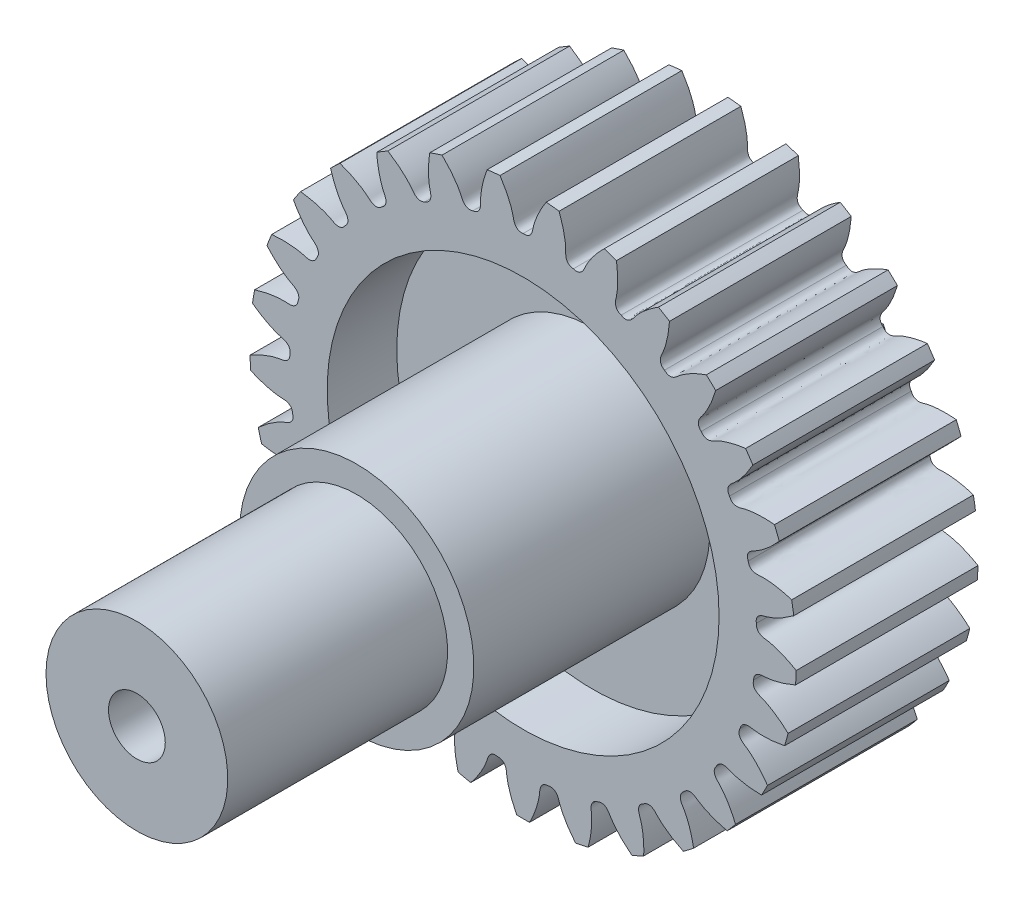
from build123d import *

# Parameters (mm, degrees)
GEAR_BASESKETCH_R                            = 9.62085945
F_0_6207_MODULE_18_0003MM_P_D_DEPTH          = 3.2
TOOTH_CUT_COARSE_PITCH_INVOLUTE_20_DEG_DEPTH = 4.2
TOOTH_PATTERN_29_29_COUNT                    = 29
SKETCH3_R                                    = 6.9
CUT_EXTRUDE5_DEPTH                           = 7.4000001
SKETCH5_R                                    = 1
CUT_EXTRUDE6_DEPTH                           = 23
BOSS_EXTRUDE2_DEPTH                          = 2.5


with BuildPart() as part:
    # Gear-BaseSketch → 0.6207 Module, 18.0003mm P.D. (new body, symmetric)
    with BuildSketch(Plane.XY):
        Circle(GEAR_BASESKETCH_R)
    extrude(amount=F_0_6207_MODULE_18_0003MM_P_D_DEPTH, both=True)

    # Tooth-Sketch; Backlash: 0.0000mm → Tooth-Cut, Coarse Pitch Involute 20 deg (cut, symmetric)
    with BuildSketch(Plane.XY):
        with BuildLine():
            ThreePointArc((-0.874573512, 9.677174392), (0, 9.716613764), (0.874573512, 9.677174392))
            add(Edge.make_bspline(
                [(0.874573512, 9.677174392), (0.810753253, 9.584844464), (0.723074056, 9.448048962), (0.621038779, 9.266226692), (0.557931311, 9.143132279), (0.504580396, 9.02865349), (0.460240286, 8.923335386), (0.42413615, 8.827679054), (0.395475422, 8.742139085), (0.37342353, 8.667126443), (0.357185949, 8.602995588), (0.347105284, 8.55622554), (0.341425051, 8.524655339), (0.337449721, 8.504838192), (0.330655529, 8.475214631), (0.319198264, 8.435173705), (0.299395753, 8.3855185), (0.272391469, 8.337048944), (0.233306546, 8.289093251), (0.149065118, 8.22525123), (0.058572624, 8.218421439), (0, 8.223999693)],
                knots=[0, 0, 0, 0, 0.188221103, 0.272248381, 0.349553478, 0.420136393, 0.483997126, 0.541135677, 0.591552047, 0.635246236, 0.672218243, 0.70246807, 0.715453139, 0.726008681, 0.736358508, 0.766417562, 0.795747205, 0.825830737, 0.85909947, 0.898928891, 1, 1, 1, 1], degree=3))
            add(Edge.make_bspline(
                [(-0.874573512, 9.677174392), (-0.810753253, 9.584844464), (-0.723074056, 9.448048962), (-0.621038779, 9.266226692), (-0.557931311, 9.143132279), (-0.504580396, 9.02865349), (-0.460240286, 8.923335386), (-0.42413615, 8.827679054), (-0.395475422, 8.742139085), (-0.37342353, 8.667126443), (-0.357185949, 8.602995588), (-0.347105284, 8.55622554), (-0.341425051, 8.524655339), (-0.337449721, 8.504838192), (-0.330655529, 8.475214631), (-0.319198264, 8.435173705), (-0.299395753, 8.3855185), (-0.272391469, 8.337048944), (-0.233306546, 8.289093251), (-0.149065118, 8.22525123), (-0.058572624, 8.218421439), (0, 8.223999693)],
                knots=[0, 0, 0, 0, 0.188221103, 0.272248381, 0.349553478, 0.420136393, 0.483997126, 0.541135677, 0.591552047, 0.635246236, 0.672218243, 0.70246807, 0.715453139, 0.726008681, 0.736358508, 0.766417562, 0.795747205, 0.825830737, 0.85909947, 0.898928891, 1, 1, 1, 1], degree=3))
        make_face()
    tooth_cut_coarse_pitch_involute_20_deg = extrude(amount=TOOTH_CUT_COARSE_PITCH_INVOLUTE_20_DEG_DEPTH, both=True, mode=Mode.SUBTRACT)

    # Tooth Pattern, 29 / 29: Tooth-Cut, Coarse Pitch Involute 20 deg ×29 about axis
    tooth_pattern_29_29_axis = Axis((0, 0, -88.99), (0, 0, 1))
    for i in range(1, TOOTH_PATTERN_29_29_COUNT):
        add(tooth_cut_coarse_pitch_involute_20_deg.rotate(tooth_pattern_29_29_axis, i * 360 / TOOTH_PATTERN_29_29_COUNT), mode=Mode.SUBTRACT)

    # Sketch3 → Cut-Extrude5 (cut, through all)
    with BuildSketch(Plane.XY.offset(3.2)):
        Circle(SKETCH3_R)
    extrude(amount=-CUT_EXTRUDE5_DEPTH, mode=Mode.SUBTRACT)

    # Sketch4 → Revolve1 (revolve)
    with BuildSketch(Plane(origin=(0, 0, 0), x_dir=(1, 0, 0), z_dir=(0, 1, 0))):
        Polygon((0, 5.2), (3.25, 5.2), (3.25, 0.75), (6.9, 0.75), (6.9, -0.75), (4.125, -0.75), (4.125, -9.06), (3.2, -9.06), (3.2, -16.8), (0, -16.8), align=None)
    revolve(axis=Axis((0, 0, -88.99), (0, 0, 1)))

    # Sketch5 → Cut-Extrude6 (cut, through all)
    with BuildSketch(Plane.XY.offset(16.8)):
        Circle(SKETCH5_R)
    extrude(amount=-CUT_EXTRUDE6_DEPTH, mode=Mode.SUBTRACT)

    # Sketch6 → Boss-Extrude2 (add)
    with BuildSketch(Plane(origin=(0, 0, -5.2), x_dir=(-1, 0, 0), z_dir=(0, 0, -1))):
        with BuildLine():
            Line((-1.78605711, 0.9), (-0.435889894, 0.9))
            ThreePointArc((-0.435889894, 0.9), (0, -1), (0.435889894, 0.9))
            Line((0.435889894, 0.9), (1.78605711, 0.9))
            ThreePointArc((1.78605711, 0.9), (0, -2), (-1.78605711, 0.9))
        make_face()
    extrude(amount=BOSS_EXTRUDE2_DEPTH)


solid = part.part
